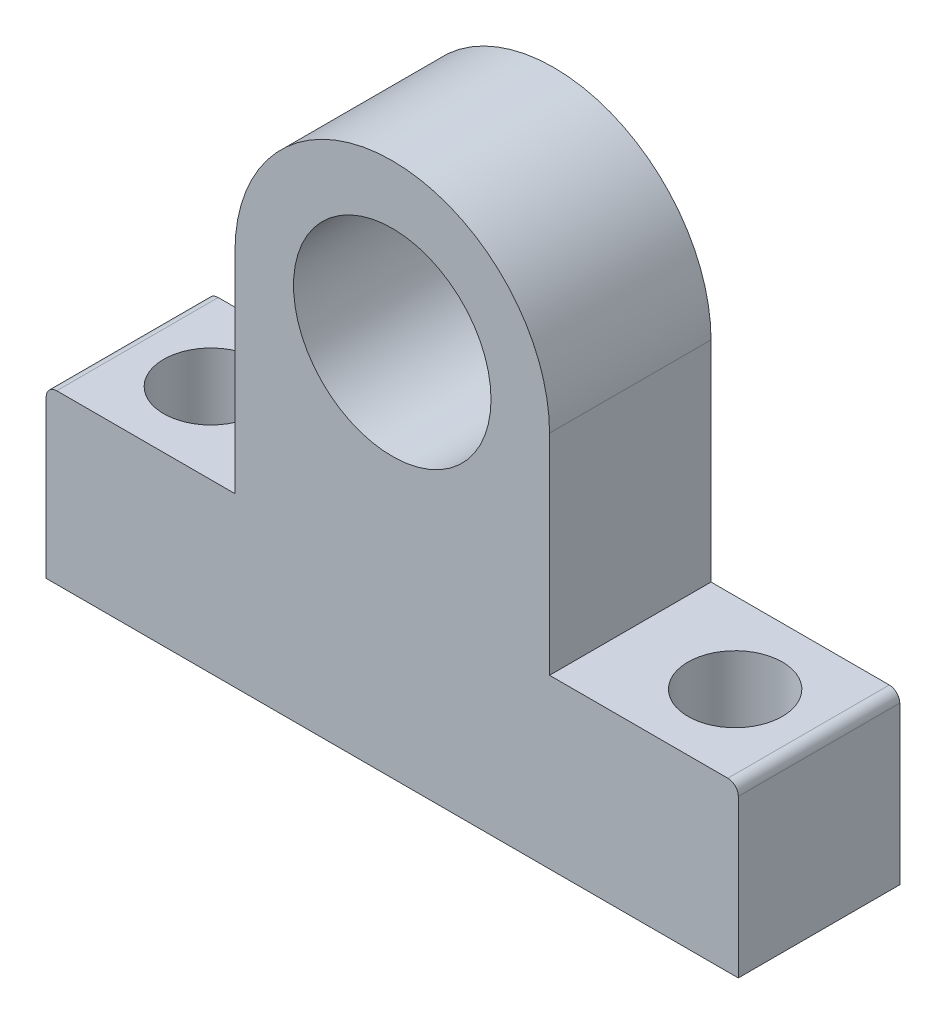
from build123d import *

# Parameters (mm, degrees)
SALIENTE_EXTRUIR1_DEPTH = 15.4
CROQUIS2_R              = 9.417866401
CORTAR_EXTRUIR1_DEPTH   = 16.4
CROQUIS3_R              = 4.5
CORTAR_EXTRUIR2_DEPTH   = 52


with BuildPart() as part:
    # Croquis1 → Saliente-Extruir1 (new body)
    with BuildSketch(Plane.XY):
        with BuildLine():
            Line((-30.267515924, 0), (-30.267515924, 15))
            ThreePointArc((-30.267515924, 15), (-29.974622705, 15.707106781), (-29.267515924, 16))
            Line((-29.267515924, 16), (-12.267515924, 16))
            Line((-12.267515924, 16), (-12.267515924, 36))
            ThreePointArc((-12.267515924, 36), (2.732484076, 51), (17.732484076, 36))
            Line((17.732484076, 36), (17.732484076, 16))
            Line((17.732484076, 16), (34.732484076, 16))
            ThreePointArc((34.732484076, 16), (35.439590858, 15.707106781), (35.732484076, 15))
            Line((35.732484076, 15), (35.732484076, 0))
            Line((35.732484076, 0), (-30.267515924, 0))
        make_face()
    extrude(amount=SALIENTE_EXTRUIR1_DEPTH)

    # Croquis2 → Cortar-Extruir1 (cut, through all)
    with BuildSketch(Plane.XY.offset(15.4)):
        with Locations((2.732484076, 36)):
            Circle(CROQUIS2_R)
    extrude(amount=-CORTAR_EXTRUIR1_DEPTH, mode=Mode.SUBTRACT)

    # Croquis3 → Cortar-Extruir2 (cut, through all)
    with BuildSketch(Plane.XZ):
        with Locations((-22.267515924, 7.7)):
            Circle(CROQUIS3_R)
        with Locations((27.732484076, 7.7)):
            Circle(CROQUIS3_R)
    extrude(amount=-CORTAR_EXTRUIR2_DEPTH, mode=Mode.SUBTRACT)


solid = part.part
